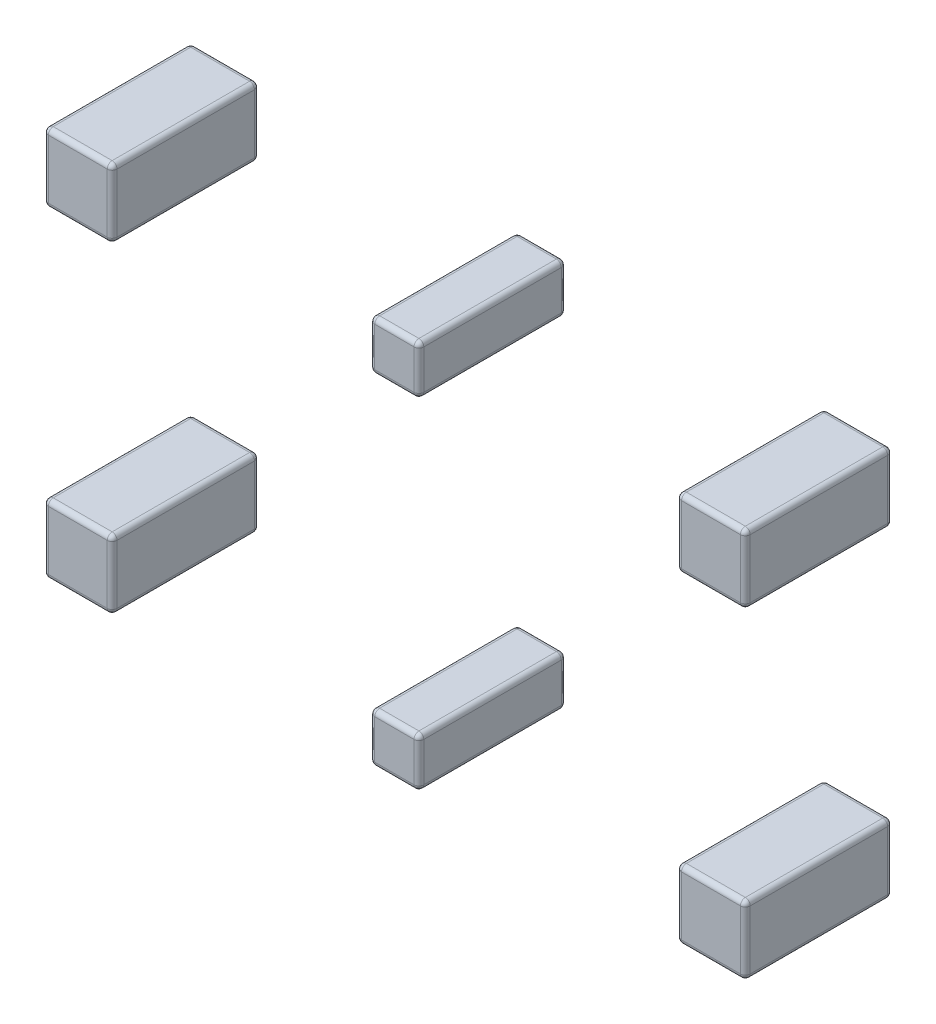
from build123d import *

# Parameters (mm, degrees)
SZKIC1_W                      = 280
SZKIC1_H                      = 280
DODANIE_WYCI_GNI_CIE1_DEPTH   = 600
SZKIC1_W_2                    = 200
SZKIC1_H_2                    = 200
DODANIE_WYCI_GNI_CIE1_2_DEPTH = 600
DODANIE_WYCI_GNI_CIE1_3_DEPTH = 600
DODANIE_WYCI_GNI_CIE1_4_DEPTH = 600
DODANIE_WYCI_GNI_CIE1_5_DEPTH = 600
DODANIE_WYCI_GNI_CIE1_6_DEPTH = 600
ZAOKR_GLENIE1_R               = 20
ZAOKR_GLENIE2_R               = 20
ZAOKR_GLENIE3_R               = 20
ZAOKR_GLENIE4_R               = 20
ZAOKR_GLENIE5_R               = 20
ZAOKR_GLENIE6_R               = 20


with BuildPart() as part:
    # Szkic1 → Dodanie-wyciągnięcie1 (new body)
    with BuildSketch(Plane(origin=(0, 0, 193), x_dir=(-1, 0, 0), z_dir=(0, 0, -1))):
        with Locations((-1223.752188602, 654.873149236)):
            Rectangle(SZKIC1_W, SZKIC1_H)
    extrude(amount=DODANIE_WYCI_GNI_CIE1_DEPTH)

    # Zaokrąglenie1
    zaokr_glenie1_edges = [part.edges().sort_by_distance(p)[0] for p in [
        (1363.752188602, 654.873149236, -407),
        (1223.752188602, 514.873149236, -407),
        (1083.752188602, 654.873149236, -407),
        (1223.752188602, 514.873149236, 193),
        (1363.752188602, 654.873149236, 193),
        (1223.752188602, 794.873149236, 193),
        (1083.752188602, 654.873149236, 193),
        (1223.752188602, 794.873149236, -407),
        (1083.752188602, 514.873149236, -107),
        (1363.752188602, 514.873149236, -107),
        (1363.752188602, 794.873149236, -107),
        (1083.752188602, 794.873149236, -107),
    ]]
    fillet(zaokr_glenie1_edges, radius=ZAOKR_GLENIE1_R)


with BuildPart() as body_2:
    # Szkic1 → Dodanie-wyci_gni_cie1 2 (new body)
    with BuildSketch(Plane(origin=(0, 0, 193), x_dir=(-1, 0, 0), z_dir=(0, 0, -1))):
        with Locations((66.247811398, 692.373149236)):
            Rectangle(SZKIC1_W_2, SZKIC1_H_2)
    extrude(amount=DODANIE_WYCI_GNI_CIE1_2_DEPTH)

    # Zaokrąglenie5
    zaokr_glenie5_edges = [body_2.edges().sort_by_distance(p)[0] for p in [
        (-166.247811398, 692.373149236, -407),
        (-66.247811398, 792.373149236, -407),
        (33.752188602, 692.373149236, -407),
        (-66.247811398, 792.373149236, 193),
        (-166.247811398, 692.373149236, 193),
        (-66.247811398, 592.373149236, 193),
        (33.752188602, 692.373149236, 193),
        (-66.247811398, 592.373149236, -407),
        (33.752188602, 792.373149236, -107),
        (-166.247811398, 792.373149236, -107),
        (-166.247811398, 592.373149236, -107),
        (33.752188602, 592.373149236, -107),
    ]]
    fillet(zaokr_glenie5_edges, radius=ZAOKR_GLENIE5_R)


with BuildPart() as body_3:
    # Szkic1 → Dodanie-wyci_gni_cie1 3 (new body)
    with BuildSketch(Plane(origin=(0, 0, 193), x_dir=(-1, 0, 0), z_dir=(0, 0, -1))):
        with Locations((1356.247811398, 654.873149236)):
            Rectangle(SZKIC1_W, SZKIC1_H)
    extrude(amount=DODANIE_WYCI_GNI_CIE1_3_DEPTH)

    # Zaokrąglenie6
    zaokr_glenie6_edges = [body_3.edges().sort_by_distance(p)[0] for p in [
        (-1216.247811398, 654.873149236, -407),
        (-1356.247811398, 514.873149236, -407),
        (-1496.247811398, 654.873149236, -407),
        (-1356.247811398, 514.873149236, 193),
        (-1216.247811398, 654.873149236, 193),
        (-1356.247811398, 794.873149236, 193),
        (-1496.247811398, 654.873149236, 193),
        (-1356.247811398, 794.873149236, -407),
        (-1496.247811398, 514.873149236, -107),
        (-1216.247811398, 514.873149236, -107),
        (-1216.247811398, 794.873149236, -107),
        (-1496.247811398, 794.873149236, -107),
    ]]
    fillet(zaokr_glenie6_edges, radius=ZAOKR_GLENIE6_R)


with BuildPart() as body_4:
    # Szkic1 → Dodanie-wyci_gni_cie1 4 (new body)
    with BuildSketch(Plane(origin=(0, 0, 193), x_dir=(-1, 0, 0), z_dir=(0, 0, -1))):
        with Locations((1356.247811398, -655.126850764)):
            Rectangle(SZKIC1_W, SZKIC1_H)
    extrude(amount=DODANIE_WYCI_GNI_CIE1_4_DEPTH)

    # Zaokrąglenie4
    zaokr_glenie4_edges = [body_4.edges().sort_by_distance(p)[0] for p in [
        (-1216.247811398, -655.126850764, -407),
        (-1356.247811398, -795.126850764, -407),
        (-1496.247811398, -655.126850764, -407),
        (-1356.247811398, -795.126850764, 193),
        (-1216.247811398, -655.126850764, 193),
        (-1356.247811398, -515.126850764, 193),
        (-1496.247811398, -655.126850764, 193),
        (-1356.247811398, -515.126850764, -407),
        (-1496.247811398, -795.126850764, -107),
        (-1216.247811398, -795.126850764, -107),
        (-1216.247811398, -515.126850764, -107),
        (-1496.247811398, -515.126850764, -107),
    ]]
    fillet(zaokr_glenie4_edges, radius=ZAOKR_GLENIE4_R)


with BuildPart() as body_5:
    # Szkic1 → Dodanie-wyci_gni_cie1 5 (new body)
    with BuildSketch(Plane(origin=(0, 0, 193), x_dir=(-1, 0, 0), z_dir=(0, 0, -1))):
        with Locations((66.247811398, -692.626850764)):
            Rectangle(SZKIC1_W_2, SZKIC1_H_2)
    extrude(amount=DODANIE_WYCI_GNI_CIE1_5_DEPTH)

    # Zaokrąglenie3
    zaokr_glenie3_edges = [body_5.edges().sort_by_distance(p)[0] for p in [
        (-166.247811398, -692.626850764, -407),
        (-66.247811398, -592.626850764, -407),
        (33.752188602, -692.626850764, -407),
        (-66.247811398, -592.626850764, 193),
        (-166.247811398, -692.626850764, 193),
        (-66.247811398, -792.626850764, 193),
        (33.752188602, -692.626850764, 193),
        (-66.247811398, -792.626850764, -407),
        (33.752188602, -592.626850764, -107),
        (-166.247811398, -592.626850764, -107),
        (-166.247811398, -792.626850764, -107),
        (33.752188602, -792.626850764, -107),
    ]]
    fillet(zaokr_glenie3_edges, radius=ZAOKR_GLENIE3_R)


with BuildPart() as body_6:
    # Szkic1 → Dodanie-wyci_gni_cie1 6 (new body)
    with BuildSketch(Plane(origin=(0, 0, 193), x_dir=(-1, 0, 0), z_dir=(0, 0, -1))):
        with Locations((-1223.752188602, -655.126850764)):
            Rectangle(SZKIC1_W, SZKIC1_H)
    extrude(amount=DODANIE_WYCI_GNI_CIE1_6_DEPTH)

    # Zaokrąglenie2
    zaokr_glenie2_edges = [body_6.edges().sort_by_distance(p)[0] for p in [
        (1363.752188602, -655.126850764, -407),
        (1223.752188602, -795.126850764, -407),
        (1083.752188602, -655.126850764, -407),
        (1223.752188602, -795.126850764, 193),
        (1363.752188602, -655.126850764, 193),
        (1223.752188602, -515.126850764, 193),
        (1083.752188602, -655.126850764, 193),
        (1223.752188602, -515.126850764, -407),
        (1083.752188602, -795.126850764, -107),
        (1363.752188602, -795.126850764, -107),
        (1363.752188602, -515.126850764, -107),
        (1083.752188602, -515.126850764, -107),
    ]]
    fillet(zaokr_glenie2_edges, radius=ZAOKR_GLENIE2_R)


solid = Compound([part.part, body_2.part, body_3.part, body_4.part, body_5.part, body_6.part])
